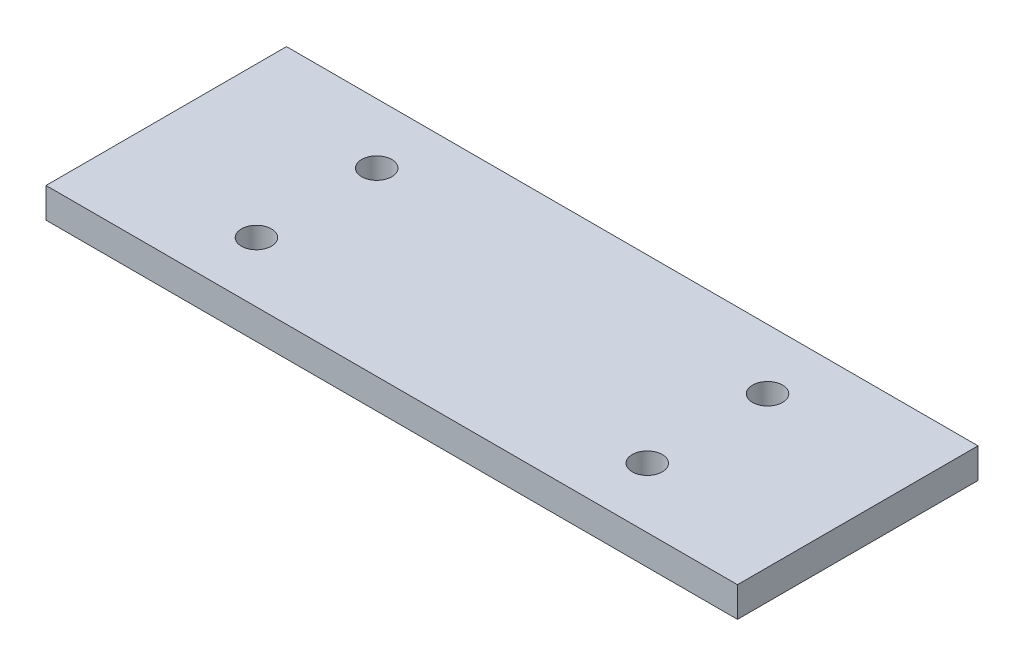
from build123d import *

# Parameters (mm, degrees)
SKETCH2_W           = 115
SKETCH2_H           = 40
SKETCH2_R           = 2.5
BOSS_EXTRUDE2_DEPTH = 5


with BuildPart() as part:
    # Sketch2 → Boss-Extrude2 (new body)
    with BuildSketch(Plane(origin=(0, 0, 0), x_dir=(1, 0, 0), z_dir=(0, 1, 0))):
        Rectangle(SKETCH2_W, SKETCH2_H)
        with Locations((-32.5, 10)):
            Circle(SKETCH2_R, mode=Mode.SUBTRACT)
        with Locations((-32.5, -10)):
            Circle(SKETCH2_R, mode=Mode.SUBTRACT)
        with Locations((32.5, 10)):
            Circle(SKETCH2_R, mode=Mode.SUBTRACT)
        with Locations((32.5, -10)):
            Circle(SKETCH2_R, mode=Mode.SUBTRACT)
    extrude(amount=BOSS_EXTRUDE2_DEPTH)


solid = part.part
